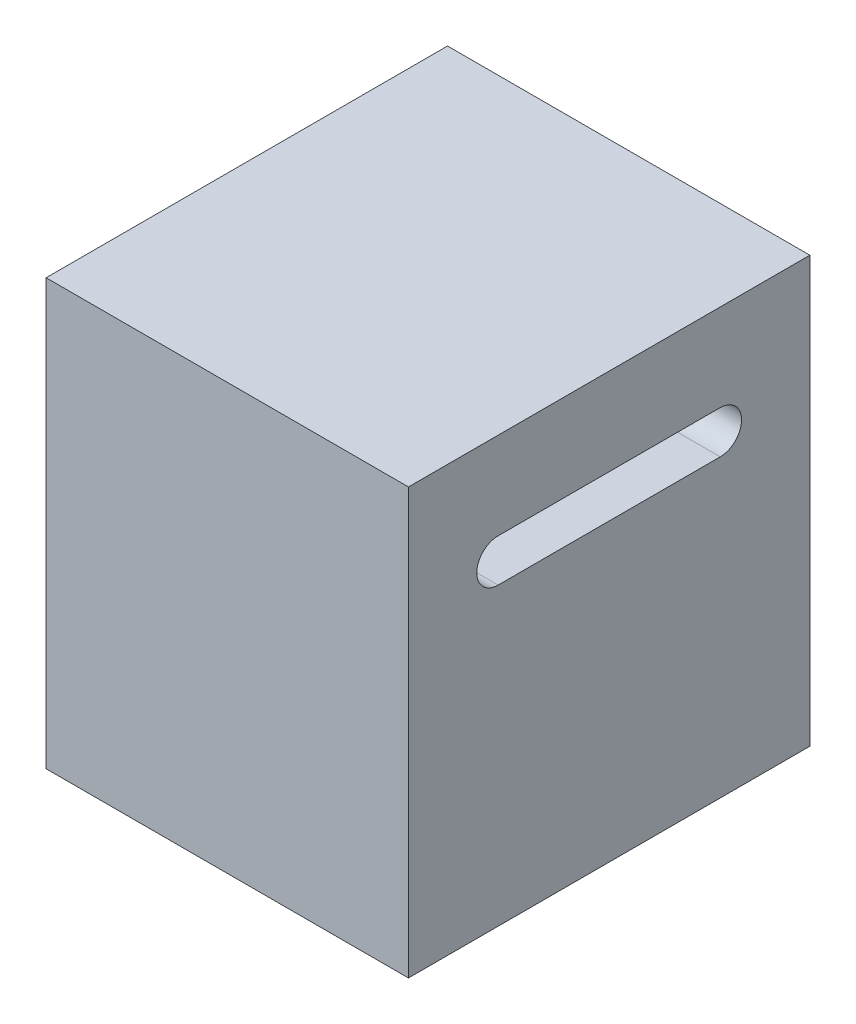
from build123d import *

# Parameters (mm, degrees)
SKETCH1_W           = 42.418
SKETCH1_H           = 46.99
BOSS_EXTRUDE1_DEPTH = 49.784
CUT_EXTRUDE1_DEPTH  = 43.418


with BuildPart() as part:
    # Sketch1 → Boss-Extrude1 (new body)
    with BuildSketch(Plane(origin=(0, 0, 0), x_dir=(1, 0, 0), z_dir=(0, 1, 0))):
        with Locations((21.209, 23.495)):
            Rectangle(SKETCH1_W, SKETCH1_H)
    extrude(amount=BOSS_EXTRUDE1_DEPTH)

    # Sketch2 → Cut-Extrude1 (cut, through all)
    with BuildSketch(Plane(origin=(42.418, 0, 0), x_dir=(0, 0, -1), z_dir=(1, 0, 0))):
        with BuildLine():
            Line((10.495, 39.580113), (36.495, 39.580113))
            ThreePointArc((36.495, 39.580113), (38.991113, 37.084), (36.495, 34.587887))
            Line((36.495, 34.587887), (10.495, 34.587887))
            ThreePointArc((10.495, 34.587887), (7.998887, 37.084), (10.495, 39.580113))
        make_face()
    extrude(amount=-CUT_EXTRUDE1_DEPTH, mode=Mode.SUBTRACT)


solid = part.part
